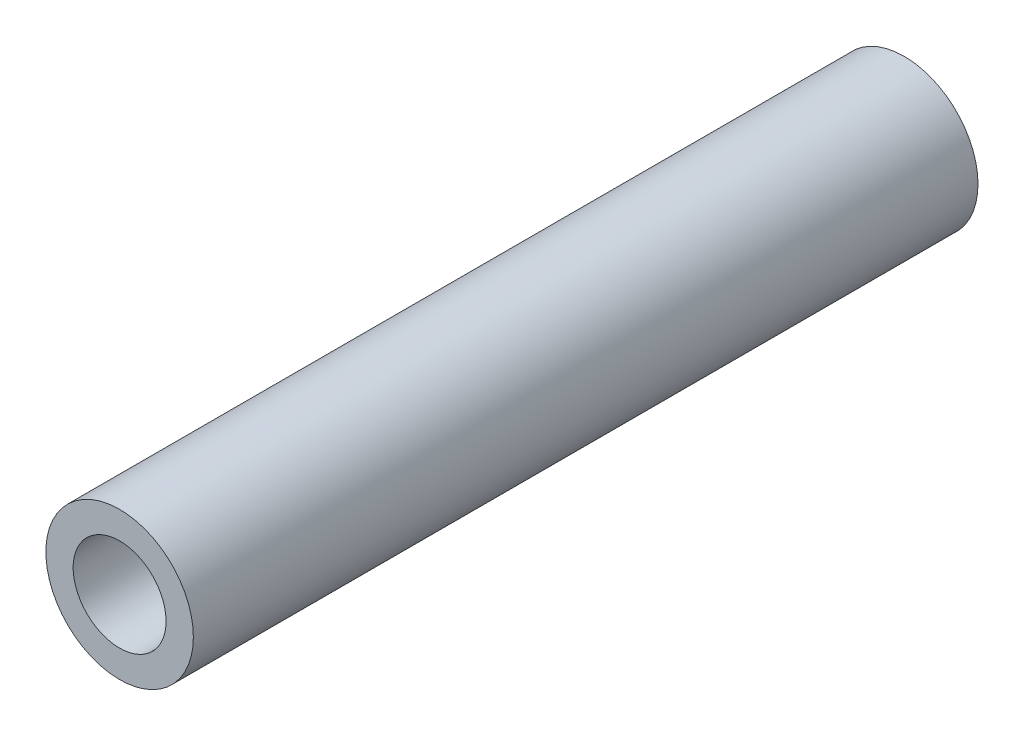
from build123d import *

# Parameters (mm, degrees)
SKETCH1_R           = 3.175
SKETCH1_R_2         = 2.286
BOSS_EXTRUDE1_DEPTH = 29.7165
SKETCH2_R           = 3.175
SKETCH2_R_2         = 2.286
BOSS_EXTRUDE2_DEPTH = 4.064
SKETCH3_R           = 2.762
SKETCH3_R_2         = 2
EXTRUDE_THIN1_DEPTH = 12.7
EXTRUDE_THIN1_TAPER = -1


with BuildPart() as part:
    # Sketch1 → Boss-Extrude1 (new body)
    with BuildSketch(Plane.XY):
        Circle(SKETCH1_R)
        Circle(SKETCH1_R_2, mode=Mode.SUBTRACT)
    extrude(amount=-BOSS_EXTRUDE1_DEPTH)

    # Sketch2 → Boss-Extrude2 (add)
    with BuildSketch(Plane(origin=(0, 0, -29.7165), x_dir=(-1, 0, 0), z_dir=(0, 0, -1))):
        Circle(SKETCH2_R)
        Circle(SKETCH2_R_2, mode=Mode.SUBTRACT)
    extrude(amount=BOSS_EXTRUDE2_DEPTH)

    # Sketch3 → Extrude-Thin1 (add)
    with BuildSketch(Plane.XY):
        Circle(SKETCH3_R)
        Circle(SKETCH3_R_2, mode=Mode.SUBTRACT)
    extrude(amount=-EXTRUDE_THIN1_DEPTH, taper=EXTRUDE_THIN1_TAPER)


solid = part.part
